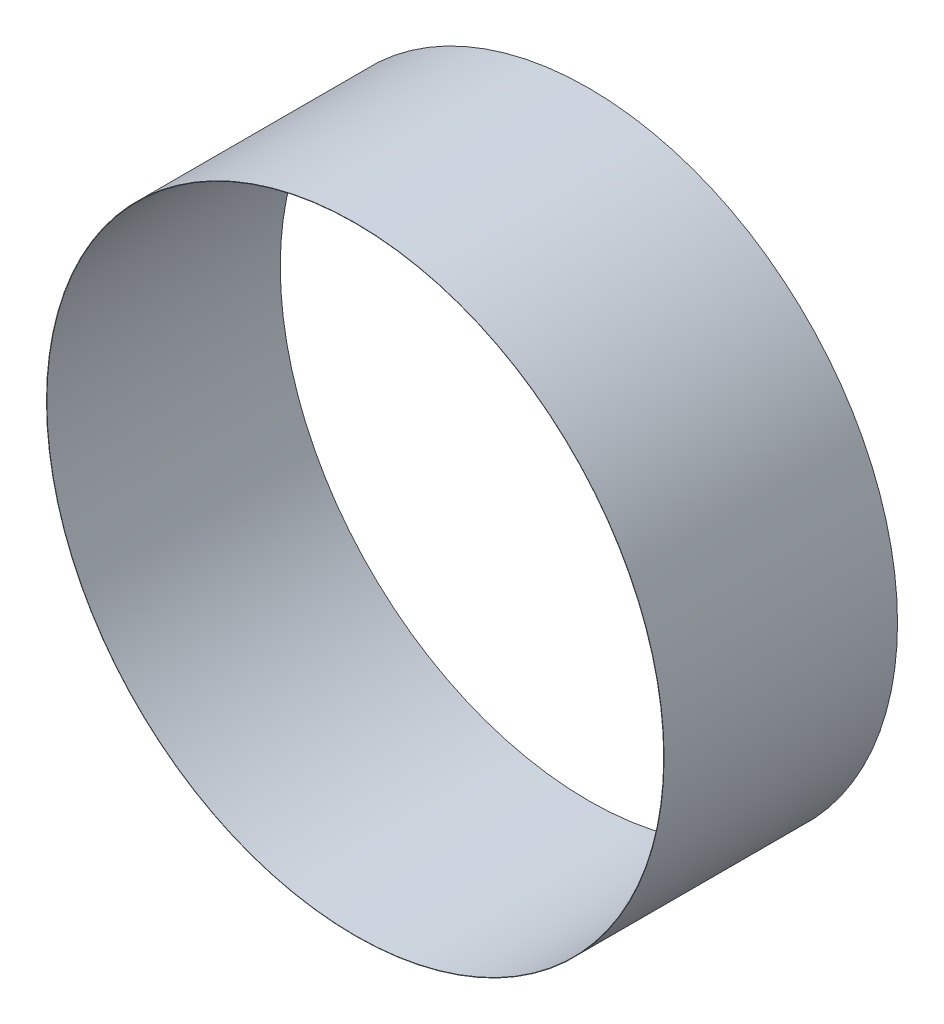
from build123d import *

# Parameters (mm, degrees)
SKETCH_1_R      = 92.6
SKETCH_1_R_2    = 92.5
EXTRUDE_1_DEPTH = 70


with BuildPart() as part:
    # 草图1 → 凸台-拉伸1 (new body)
    with BuildSketch(Plane.XY):
        Circle(SKETCH_1_R)
        Circle(SKETCH_1_R_2, mode=Mode.SUBTRACT)
    extrude(amount=EXTRUDE_1_DEPTH)


solid = part.part
